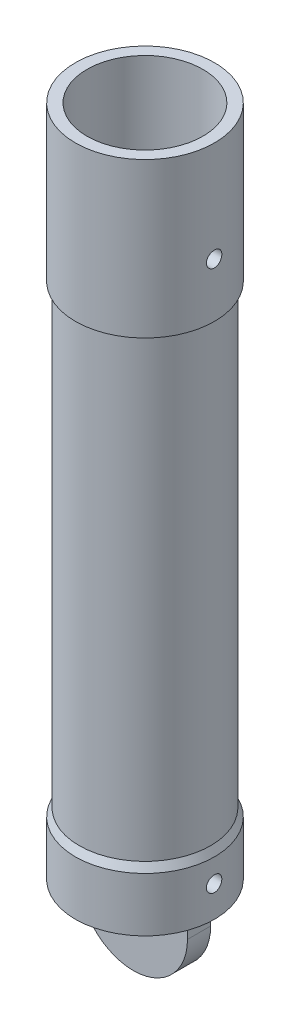
from build123d import *

# Parameters (mm, degrees)
BOSS_EXTRUDE1_DEPTH      = 1.5
BOSS_EXTRUDE1_DEPTH_BACK = 1.5
SKETCH2_R                = 2
SKETCH3_R                = 1
CUT_EXTRUDE1_DEPTH       = 50


with BuildPart() as part:
    # Sketch1 → Revolve1 (revolve)
    with BuildSketch(Plane.XY):
        Polygon((0, 0), (-9, 0), (-9, 7), (-8.5, 8), (-8.5, 67), (-9, 67), (-9, 87), (-7.5, 87), (-7.5, 2), (0, 2), align=None)
    revolve(axis=Axis((0, 87, 0), (0, -1, 0)))

    # Sketch2 → Boss-Extrude1 (add, two sides: drawn at the far end of the back side and taken through both)
    with BuildSketch(Plane.XY.offset(-BOSS_EXTRUDE1_DEPTH_BACK)):
        with BuildLine():
            Line((-7, 0), (7, 0))
            Line((7, 0), (7, -2.5))
            ThreePointArc((7, -2.5), (0, -9.5), (-7, -2.5))
            Line((-7, -2.5), (-7, 0))
        make_face()
        with Locations((0, -2.5)):
            Circle(SKETCH2_R, mode=Mode.SUBTRACT)
    extrude(amount=BOSS_EXTRUDE1_DEPTH + BOSS_EXTRUDE1_DEPTH_BACK)

    # Sketch3 → Cut-Extrude1 (cut)
    with BuildSketch(Plane(origin=(0, 0, 0), x_dir=(0, 0, -1), z_dir=(1, 0, 0))):
        with Locations((0, 74)):
            Circle(SKETCH3_R)
        with Locations((0, 4)):
            Circle(SKETCH3_R)
    extrude(amount=CUT_EXTRUDE1_DEPTH, mode=Mode.SUBTRACT)


solid = part.part
